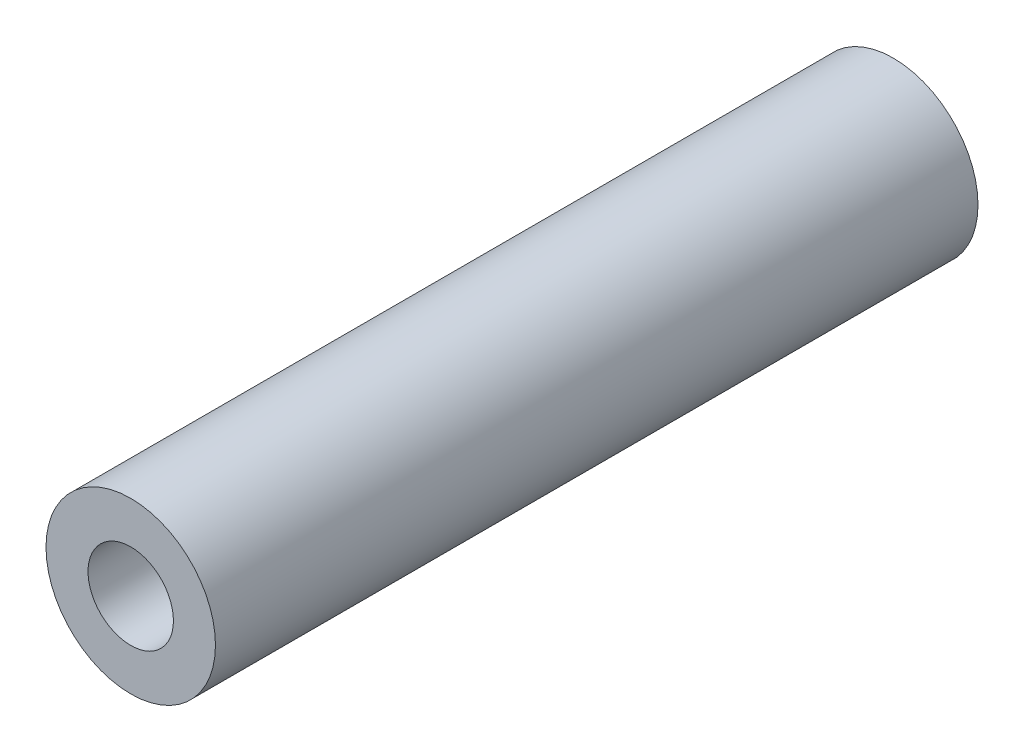
from build123d import *

# Parameters (mm, degrees)
SKETCH1_R      = 6.35
SKETCH1_R_2    = 3.2004
EXTRUDE1_DEPTH = 28.575


with BuildPart() as part:
    # Sketch1 → Extrude1 (new body, symmetric)
    with BuildSketch(Plane.XY):
        Circle(SKETCH1_R)
        Circle(SKETCH1_R_2, mode=Mode.SUBTRACT)
    extrude(amount=EXTRUDE1_DEPTH, both=True)


solid = part.part
